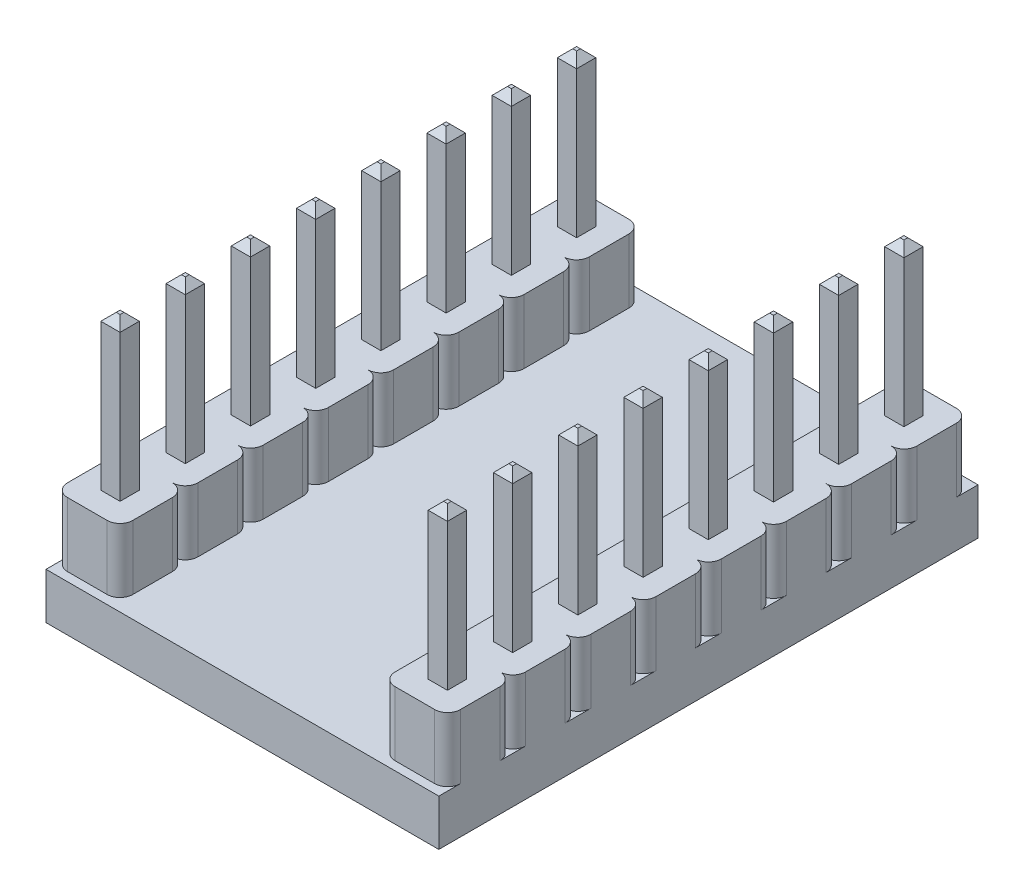
from build123d import *

# Parameters (mm, degrees)
ESQUISSE1_W             = 15.3
ESQUISSE1_H             = 21
BOSS_EXTRU_1_DEPTH      = 1.8
ESQUISSE2_W             = 0.75
ESQUISSE2_H             = 0.75
BOSS_EXTRU_2_DEPTH      = 8.5
BOSS_EXTRU_2_DEPTH_BACK = 2.95
CHANFREIN1_SIZE         = 0.3
BOSS_EXTRU_4_DEPTH      = 2.5
CONG_1_R                = 0.5


with BuildPart() as part:
    # Esquisse1 → Boss.-Extru.1 (new body)
    with BuildSketch(Plane(origin=(0, 0, 0), x_dir=(1, 0, 0), z_dir=(0, 1, 0))):
        with Locations((7.65, 10.5)):
            Rectangle(ESQUISSE1_W, ESQUISSE1_H)
    extrude(amount=BOSS_EXTRU_1_DEPTH)

    # Esquisse2 → Boss.-Extru.2 (add, two sides)
    with BuildSketch(Plane(origin=(0, 1.8, 0), x_dir=(1, 0, 0), z_dir=(0, 1, 0))) as boss_extru_2_sk:
        with Locations((1.275, 11.77)):
            Rectangle(ESQUISSE2_W, ESQUISSE2_H)
        with Locations((1.275, 16.85)):
            Rectangle(ESQUISSE2_W, ESQUISSE2_H)
        with Locations((1.275, 14.31)):
            Rectangle(ESQUISSE2_W, ESQUISSE2_H)
        with Locations((1.275, 19.39)):
            Rectangle(ESQUISSE2_W, ESQUISSE2_H)
        with Locations((1.275, 9.23)):
            Rectangle(ESQUISSE2_W, ESQUISSE2_H)
        with Locations((1.275, 6.69)):
            Rectangle(ESQUISSE2_W, ESQUISSE2_H)
        with Locations((1.275, 4.15)):
            Rectangle(ESQUISSE2_W, ESQUISSE2_H)
        with Locations((1.275, 1.61)):
            Rectangle(ESQUISSE2_W, ESQUISSE2_H)
        with Locations((14.025, 19.39)):
            Rectangle(ESQUISSE2_W, ESQUISSE2_H)
        with Locations((14.025, 16.85)):
            Rectangle(ESQUISSE2_W, ESQUISSE2_H)
        with Locations((14.025, 14.31)):
            Rectangle(ESQUISSE2_W, ESQUISSE2_H)
        with Locations((14.025, 11.77)):
            Rectangle(ESQUISSE2_W, ESQUISSE2_H)
        with Locations((14.025, 9.23)):
            Rectangle(ESQUISSE2_W, ESQUISSE2_H)
        with Locations((14.025, 6.69)):
            Rectangle(ESQUISSE2_W, ESQUISSE2_H)
        with Locations((14.025, 4.15)):
            Rectangle(ESQUISSE2_W, ESQUISSE2_H)
        with Locations((14.025, 1.61)):
            Rectangle(ESQUISSE2_W, ESQUISSE2_H)
    extrude(amount=BOSS_EXTRU_2_DEPTH)
    extrude(boss_extru_2_sk.sketch, amount=-BOSS_EXTRU_2_DEPTH_BACK)

    # Chanfrein1
    chanfrein1_edges = [part.edges().sort_by_distance(p)[0] for p in [
        (1.275, 10.3, -9.605),
        (0.9, 10.3, -9.23),
        (1.275, 10.3, -8.855),
        (1.65, 10.3, -9.23),
        (1.275, -1.15, -7.065),
        (1.65, -1.15, -6.69),
        (1.275, -1.15, -6.315),
        (0.9, -1.15, -6.69),
        (1.275, 10.3, -7.065),
        (0.9, 10.3, -6.69),
        (1.275, 10.3, -6.315),
        (1.65, 10.3, -6.69),
        (1.275, -1.15, -4.525),
        (1.65, -1.15, -4.15),
        (1.275, -1.15, -3.775),
        (0.9, -1.15, -4.15),
        (1.275, 10.3, -4.525),
        (0.9, 10.3, -4.15),
        (1.275, 10.3, -3.775),
        (1.65, 10.3, -4.15),
        (1.275, -1.15, -1.985),
        (1.65, -1.15, -1.61),
        (1.275, -1.15, -1.235),
        (0.9, -1.15, -1.61),
        (1.275, 10.3, -1.985),
        (0.9, 10.3, -1.61),
        (1.275, 10.3, -1.235),
        (1.65, 10.3, -1.61),
        (14.025, -1.15, -19.015),
        (13.65, -1.15, -19.39),
        (14.025, -1.15, -19.765),
        (14.4, -1.15, -19.39),
        (14.025, 10.3, -19.015),
        (14.4, 10.3, -19.39),
        (14.025, 10.3, -19.765),
        (13.65, 10.3, -19.39),
        (0.9, -1.15, -11.77),
        (1.275, -1.15, -12.145),
        (1.65, -1.15, -11.77),
        (14.025, -1.15, -16.475),
        (13.65, -1.15, -16.85),
        (14.025, -1.15, -17.225),
        (14.4, -1.15, -16.85),
        (14.025, 10.3, -16.475),
        (14.4, 10.3, -16.85),
        (14.025, 10.3, -17.225),
        (13.65, 10.3, -16.85),
        (1.275, -1.15, -11.395),
        (0.9, 10.3, -11.77),
        (1.275, 10.3, -11.395),
        (1.65, 10.3, -11.77),
        (1.275, 10.3, -12.145),
        (14.025, -1.15, -13.935),
        (13.65, -1.15, -14.31),
        (14.025, -1.15, -14.685),
        (14.4, -1.15, -14.31),
        (14.025, 10.3, -13.935),
        (14.4, 10.3, -14.31),
        (14.025, 10.3, -14.685),
        (13.65, 10.3, -14.31),
        (14.025, -1.15, -11.395),
        (13.65, -1.15, -11.77),
        (14.025, -1.15, -12.145),
        (14.4, -1.15, -11.77),
        (14.025, 10.3, -11.395),
        (14.4, 10.3, -11.77),
        (14.025, 10.3, -12.145),
        (13.65, 10.3, -11.77),
        (14.4, -1.15, -9.23),
        (14.025, -1.15, -8.855),
        (13.65, -1.15, -9.23),
        (14.025, -1.15, -9.605),
        (14.4, 10.3, -9.23),
        (14.025, 10.3, -9.605),
        (13.65, 10.3, -9.23),
        (14.025, 10.3, -8.855),
        (14.4, -1.15, -6.69),
        (14.025, -1.15, -6.315),
        (13.65, -1.15, -6.69),
        (14.025, -1.15, -7.065),
        (14.4, 10.3, -6.69),
        (14.025, 10.3, -7.065),
        (13.65, 10.3, -6.69),
        (14.025, 10.3, -6.315),
        (14.4, -1.15, -4.15),
        (14.025, -1.15, -3.775),
        (13.65, -1.15, -4.15),
        (14.025, -1.15, -4.525),
        (14.4, 10.3, -4.15),
        (14.025, 10.3, -4.525),
        (13.65, 10.3, -4.15),
        (14.025, 10.3, -3.775),
        (14.4, -1.15, -1.61),
        (14.025, -1.15, -1.235),
        (13.65, -1.15, -1.61),
        (14.025, -1.15, -1.985),
        (14.4, 10.3, -1.61),
        (14.025, 10.3, -1.985),
        (13.65, 10.3, -1.61),
        (14.025, 10.3, -1.235),
        (0.9, -1.15, -16.85),
        (1.275, -1.15, -17.225),
        (1.65, -1.15, -16.85),
        (1.275, -1.15, -16.475),
        (0.9, 10.3, -16.85),
        (1.275, 10.3, -16.475),
        (1.65, 10.3, -16.85),
        (1.275, 10.3, -17.225),
        (0.9, -1.15, -14.31),
        (1.275, -1.15, -14.685),
        (1.65, -1.15, -14.31),
        (1.275, -1.15, -13.935),
        (0.9, 10.3, -14.31),
        (1.275, 10.3, -13.935),
        (1.65, 10.3, -14.31),
        (1.275, 10.3, -14.685),
        (0.9, -1.15, -19.39),
        (1.275, -1.15, -19.765),
        (1.65, -1.15, -19.39),
        (1.275, -1.15, -19.015),
        (0.9, 10.3, -19.39),
        (1.275, 10.3, -19.015),
        (1.65, 10.3, -19.39),
        (1.275, 10.3, -19.765),
        (1.275, -1.15, -9.605),
        (1.65, -1.15, -9.23),
        (1.275, -1.15, -8.855),
        (0.9, -1.15, -9.23),
    ]]
    chamfer(chanfrein1_edges, length=CHANFREIN1_SIZE)

    # Esquisse3 → Boss.-Extru.4 (add)
    with BuildSketch(Plane(origin=(0, 1.8, 0), x_dir=(1, 0, 0), z_dir=(0, 1, 0))):
        with BuildLine():
            Line((13.26, 10.5), (14.8, 10.5))
            ThreePointArc((14.8, 10.5), (15.153553391, 10.353553391), (15.3, 10))
            Line((15.3, 10), (15.3, 8.46))
            ThreePointArc((15.3, 8.46), (15.153553391, 8.106446609), (14.8, 7.96))
            ThreePointArc((14.8, 7.96), (15.153553391, 7.813553391), (15.3, 7.46))
            Line((15.3, 7.46), (15.3, 5.92))
            ThreePointArc((15.3, 5.92), (15.153553391, 5.566446609), (14.8, 5.42))
            ThreePointArc((14.8, 5.42), (15.153553391, 5.273553391), (15.3, 4.92))
            Line((15.3, 4.92), (15.3, 3.38))
            ThreePointArc((15.3, 3.38), (15.153553391, 3.026446609), (14.8, 2.88))
            ThreePointArc((14.8, 2.88), (15.153553391, 2.733553391), (15.3, 2.38))
            Line((15.3, 2.38), (15.3, 0.84))
            ThreePointArc((15.3, 0.84), (15.153553391, 0.486446609), (14.8, 0.34))
            Line((14.8, 0.34), (13.26, 0.34))
            ThreePointArc((13.26, 0.34), (12.906446609, 0.486446609), (12.76, 0.84))
            Line((12.76, 0.84), (12.76, 2.38))
            ThreePointArc((12.76, 2.38), (12.906446609, 2.733553391), (13.26, 2.88))
            ThreePointArc((13.26, 2.88), (12.906446609, 3.026446609), (12.76, 3.38))
            Line((12.76, 3.38), (12.76, 4.92))
            ThreePointArc((12.76, 4.92), (12.906446609, 5.273553391), (13.26, 5.42))
            ThreePointArc((13.26, 5.42), (12.906446609, 5.566446609), (12.76, 5.92))
            Line((12.76, 5.92), (12.76, 7.46))
            ThreePointArc((12.76, 7.46), (12.906446609, 7.813553391), (13.26, 7.96))
            ThreePointArc((13.26, 7.96), (12.906446609, 8.106446609), (12.76, 8.46))
            Line((12.76, 8.46), (12.76, 10))
            ThreePointArc((12.76, 10), (12.906446609, 10.353553391), (13.26, 10.5))
        make_face()
        with BuildLine():
            Line((13.26, 20.66), (14.8, 20.66))
            ThreePointArc((14.8, 20.66), (15.153553391, 20.513553391), (15.3, 20.16))
            Line((15.3, 20.16), (15.3, 18.62))
            ThreePointArc((15.3, 18.62), (15.153553391, 18.266446609), (14.8, 18.12))
            ThreePointArc((14.8, 18.12), (15.153553391, 17.973553391), (15.3, 17.62))
            Line((15.3, 17.62), (15.3, 16.08))
            ThreePointArc((15.3, 16.08), (15.153553391, 15.726446609), (14.8, 15.58))
            ThreePointArc((14.8, 15.58), (15.153553391, 15.433553391), (15.3, 15.08))
            Line((15.3, 15.08), (15.3, 13.54))
            ThreePointArc((15.3, 13.54), (15.153553391, 13.186446609), (14.8, 13.04))
            ThreePointArc((14.8, 13.04), (15.153553391, 12.893553391), (15.3, 12.54))
            Line((15.3, 12.54), (15.3, 11))
            ThreePointArc((15.3, 11), (15.153553391, 10.646446609), (14.8, 10.5))
            Line((14.8, 10.5), (13.26, 10.5))
            ThreePointArc((13.26, 10.5), (12.906446609, 10.646446609), (12.76, 11))
            Line((12.76, 11), (12.76, 12.54))
            ThreePointArc((12.76, 12.54), (12.906446609, 12.893553391), (13.26, 13.04))
            ThreePointArc((13.26, 13.04), (12.906446609, 13.186446609), (12.76, 13.54))
            Line((12.76, 13.54), (12.76, 15.08))
            ThreePointArc((12.76, 15.08), (12.906446609, 15.433553391), (13.26, 15.58))
            ThreePointArc((13.26, 15.58), (12.906446609, 15.726446609), (12.76, 16.08))
            Line((12.76, 16.08), (12.76, 17.62))
            ThreePointArc((12.76, 17.62), (12.906446609, 17.973553391), (13.26, 18.12))
            ThreePointArc((13.26, 18.12), (12.906446609, 18.266446609), (12.76, 18.62))
            Line((12.76, 18.62), (12.76, 20.16))
            ThreePointArc((12.76, 20.16), (12.906446609, 20.513553391), (13.26, 20.66))
        make_face()
        with BuildLine():
            Line((2.04, 10.5), (0.5, 10.5))
            ThreePointArc((0.5, 10.5), (0.146446609, 10.646446609), (0, 11))
            Line((0, 11), (0, 12.54))
            ThreePointArc((0, 12.54), (0.146446609, 12.893553391), (0.5, 13.04))
            ThreePointArc((0.5, 13.04), (0.146446609, 13.186446609), (0, 13.54))
            Line((0, 13.54), (0, 15.08))
            ThreePointArc((0, 15.08), (0.146446609, 15.433553391), (0.5, 15.58))
            ThreePointArc((0.5, 15.58), (0.146446609, 15.726446609), (0, 16.08))
            Line((0, 16.08), (0, 17.62))
            ThreePointArc((0, 17.62), (0.146446609, 17.973553391), (0.5, 18.12))
            ThreePointArc((0.5, 18.12), (0.146446609, 18.266446609), (0, 18.62))
            Line((0, 18.62), (0, 20.16))
            ThreePointArc((0, 20.16), (0.146446609, 20.513553391), (0.5, 20.66))
            Line((0.5, 20.66), (2.04, 20.66))
            ThreePointArc((2.04, 20.66), (2.393553391, 20.513553391), (2.54, 20.16))
            Line((2.54, 20.16), (2.54, 18.62))
            ThreePointArc((2.54, 18.62), (2.393553391, 18.266446609), (2.04, 18.12))
            ThreePointArc((2.04, 18.12), (2.393553391, 17.973553391), (2.54, 17.62))
            Line((2.54, 17.62), (2.54, 16.08))
            ThreePointArc((2.54, 16.08), (2.393553391, 15.726446609), (2.04, 15.58))
            ThreePointArc((2.04, 15.58), (2.393553391, 15.433553391), (2.54, 15.08))
            Line((2.54, 15.08), (2.54, 13.54))
            ThreePointArc((2.54, 13.54), (2.393553391, 13.186446609), (2.04, 13.04))
            ThreePointArc((2.04, 13.04), (2.393553391, 12.893553391), (2.54, 12.54))
            Line((2.54, 12.54), (2.54, 11))
            ThreePointArc((2.54, 11), (2.393553391, 10.646446609), (2.04, 10.5))
        make_face()
        with BuildLine():
            Line((2.04, 0.34), (0.5, 0.34))
            ThreePointArc((0.5, 0.34), (0.146446609, 0.486446609), (0, 0.84))
            Line((0, 0.84), (0, 2.38))
            ThreePointArc((0, 2.38), (0.146446609, 2.733553391), (0.5, 2.88))
            ThreePointArc((0.5, 2.88), (0.146446609, 3.026446609), (0, 3.38))
            Line((0, 3.38), (0, 4.92))
            ThreePointArc((0, 4.92), (0.146446609, 5.273553391), (0.5, 5.42))
            ThreePointArc((0.5, 5.42), (0.146446609, 5.566446609), (0, 5.92))
            Line((0, 5.92), (0, 7.46))
            ThreePointArc((0, 7.46), (0.146446609, 7.813553391), (0.5, 7.96))
            ThreePointArc((0.5, 7.96), (0.146446609, 8.106446609), (0, 8.46))
            Line((0, 8.46), (0, 10))
            ThreePointArc((0, 10), (0.146446609, 10.353553391), (0.5, 10.5))
            Line((0.5, 10.5), (2.04, 10.5))
            ThreePointArc((2.04, 10.5), (2.393553391, 10.353553391), (2.54, 10))
            Line((2.54, 10), (2.54, 8.46))
            ThreePointArc((2.54, 8.46), (2.393553391, 8.106446609), (2.04, 7.96))
            ThreePointArc((2.04, 7.96), (2.393553391, 7.813553391), (2.54, 7.46))
            Line((2.54, 7.46), (2.54, 5.92))
            ThreePointArc((2.54, 5.92), (2.393553391, 5.566446609), (2.04, 5.42))
            ThreePointArc((2.04, 5.42), (2.393553391, 5.273553391), (2.54, 4.92))
            Line((2.54, 4.92), (2.54, 3.38))
            ThreePointArc((2.54, 3.38), (2.393553391, 3.026446609), (2.04, 2.88))
            ThreePointArc((2.04, 2.88), (2.393553391, 2.733553391), (2.54, 2.38))
            Line((2.54, 2.38), (2.54, 0.84))
            ThreePointArc((2.54, 0.84), (2.393553391, 0.486446609), (2.04, 0.34))
        make_face()
    extrude(amount=BOSS_EXTRU_4_DEPTH)

    # Congé1
    cong_1_edges = [part.edges().sort_by_distance(p)[0] for p in [
        (0.9, 0, -6.69),
        (1.275, 0, -6.315),
        (1.65, 0, -6.69),
        (1.275, 0, -7.065),
        (0.9, 0, -4.15),
        (1.275, 0, -3.775),
        (1.65, 0, -4.15),
        (1.275, 0, -4.525),
        (1.275, 0, -11.395),
        (1.65, 0, -11.77),
        (1.275, 0, -12.145),
        (0.9, 0, -11.77),
        (0.9, 0, -1.61),
        (1.275, 0, -1.235),
        (1.65, 0, -1.61),
        (1.275, 0, -1.985),
        (14.4, 0, -19.39),
        (14.025, 0, -19.765),
        (13.65, 0, -19.39),
        (14.025, 0, -19.015),
        (14.4, 0, -16.85),
        (14.025, 0, -17.225),
        (13.65, 0, -16.85),
        (14.025, 0, -16.475),
        (14.4, 0, -14.31),
        (14.025, 0, -14.685),
        (13.65, 0, -14.31),
        (14.025, 0, -13.935),
        (14.4, 0, -11.77),
        (14.025, 0, -12.145),
        (13.65, 0, -11.77),
        (14.025, 0, -11.395),
        (14.025, 0, -9.605),
        (13.65, 0, -9.23),
        (14.025, 0, -8.855),
        (14.4, 0, -9.23),
        (14.025, 0, -7.065),
        (13.65, 0, -6.69),
        (14.025, 0, -6.315),
        (14.4, 0, -6.69),
        (14.025, 0, -4.525),
        (13.65, 0, -4.15),
        (14.025, 0, -3.775),
        (14.4, 0, -4.15),
        (14.025, 0, -1.985),
        (13.65, 0, -1.61),
        (14.025, 0, -1.235),
        (14.4, 0, -1.61),
        (1.275, 0, -16.475),
        (1.65, 0, -16.85),
        (1.275, 0, -17.225),
        (0.9, 0, -16.85),
        (1.275, 0, -13.935),
        (1.65, 0, -14.31),
        (1.275, 0, -14.685),
        (0.9, 0, -14.31),
        (1.275, 0, -19.015),
        (1.65, 0, -19.39),
        (1.275, 0, -19.765),
        (0.9, 0, -19.39),
        (0.9, 0, -9.23),
        (1.275, 0, -8.855),
        (1.65, 0, -9.23),
        (1.275, 0, -9.605),
    ]]
    fillet(cong_1_edges, radius=CONG_1_R)


solid = part.part
